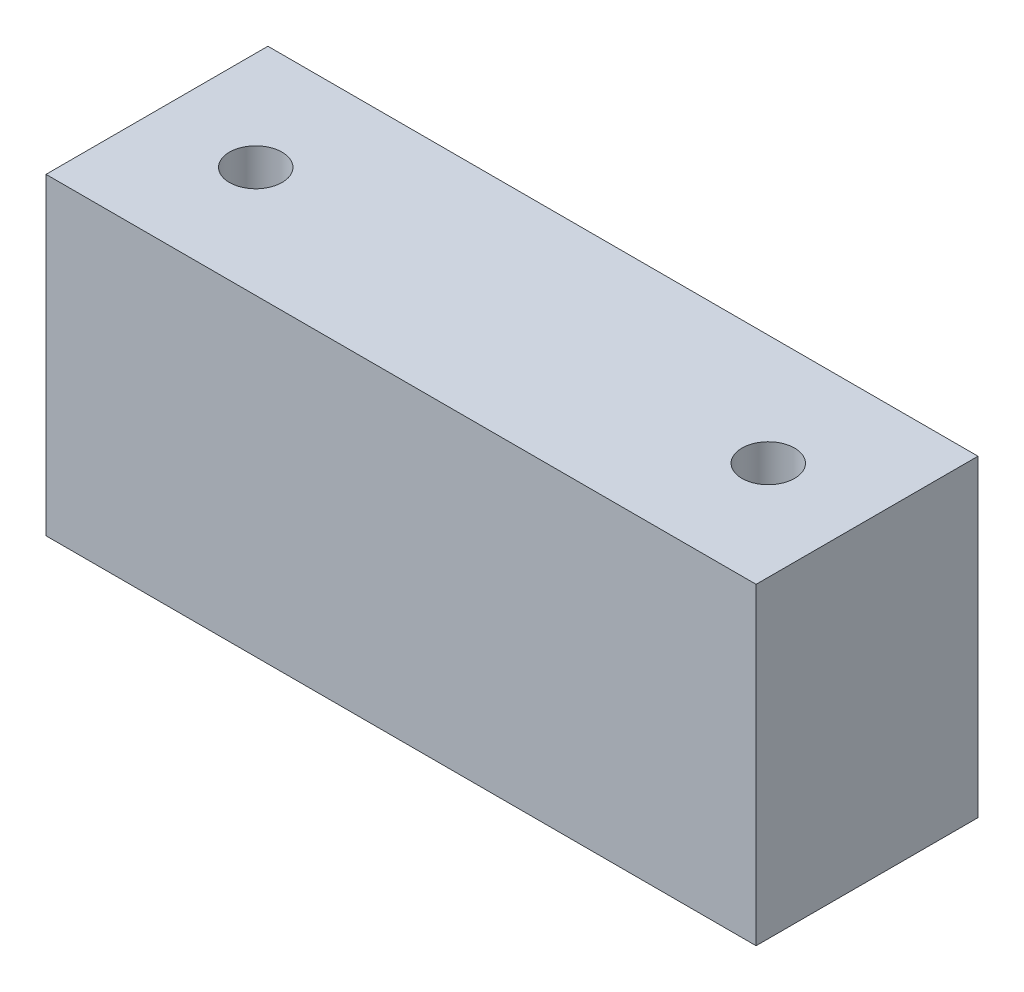
from build123d import *

# Parameters (mm, degrees)
SKETCH1_W           = 30.48
SKETCH1_H           = 9.525
BOSS_EXTRUDE1_DEPTH = 13.4366
SKETCH2_R           = 1.1303
CUT_EXTRUDE1_DEPTH  = 14.4366


with BuildPart() as part:
    # Sketch1 → Boss-Extrude1 (new body)
    with BuildSketch(Plane(origin=(0, 0, 0), x_dir=(1, 0, 0), z_dir=(0, 1, 0))):
        Rectangle(SKETCH1_W, SKETCH1_H)
    extrude(amount=BOSS_EXTRUDE1_DEPTH)

    # Sketch2 → Cut-Extrude1 (cut, through all)
    with BuildSketch(Plane(origin=(0, 13.4366, 0), x_dir=(1, 0, 0), z_dir=(0, 1, 0))):
        with Locations((-11, 0)):
            Circle(SKETCH2_R)
        with Locations((11, 0)):
            Circle(SKETCH2_R)
    extrude(amount=-CUT_EXTRUDE1_DEPTH, mode=Mode.SUBTRACT)


solid = part.part
